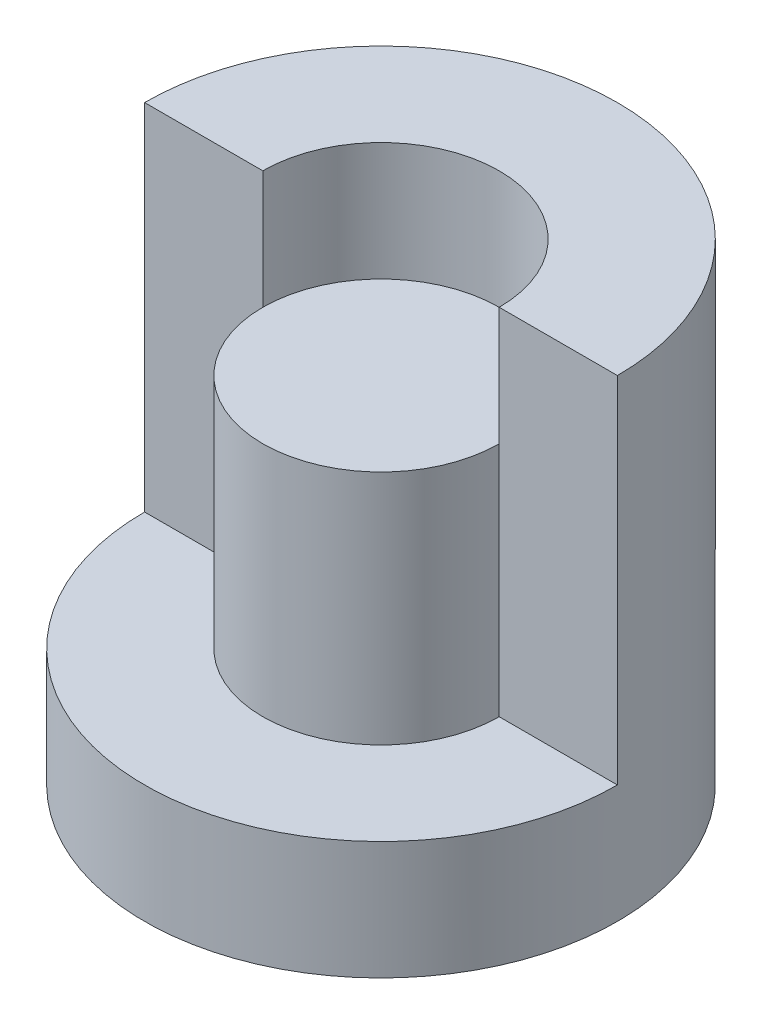
from build123d import *

# Parameters (mm, degrees)
SKETCH1_W          = 10
SKETCH1_H          = 20
SKETCH2_R          = 5
CUT_EXTRUDE5_DEPTH = 5
CUT_EXTRUDE6_DEPTH = 15


with BuildPart() as part:
    # Sketch1 → Revolve1 (revolve)
    with BuildSketch(Plane.XY):
        with Locations((5, 10)):
            Rectangle(SKETCH1_W, SKETCH1_H)
    revolve(axis=Axis((0, 0, 0), (0, 1, 0)))

    # Sketch2 → Cut-Extrude5 (cut)
    with BuildSketch(Plane(origin=(0, 20, 0), x_dir=(1, 0, 0), z_dir=(0, 1, 0))):
        Circle(SKETCH2_R)
    extrude(amount=-CUT_EXTRUDE5_DEPTH, mode=Mode.SUBTRACT)

    # Sketch5 → Cut-Extrude6 (cut)
    with BuildSketch(Plane(origin=(0, 20, 0), x_dir=(1, 0, 0), z_dir=(0, 1, 0))):
        with BuildLine():
            Line((-10, 0), (-5, 0))
            ThreePointArc((-5, 0), (0, -5), (5, 0))
            Line((5, 0), (10, 0))
            ThreePointArc((10, 0), (0, -10), (-10, 0))
        make_face()
    extrude(amount=-CUT_EXTRUDE6_DEPTH, mode=Mode.SUBTRACT)


solid = part.part
